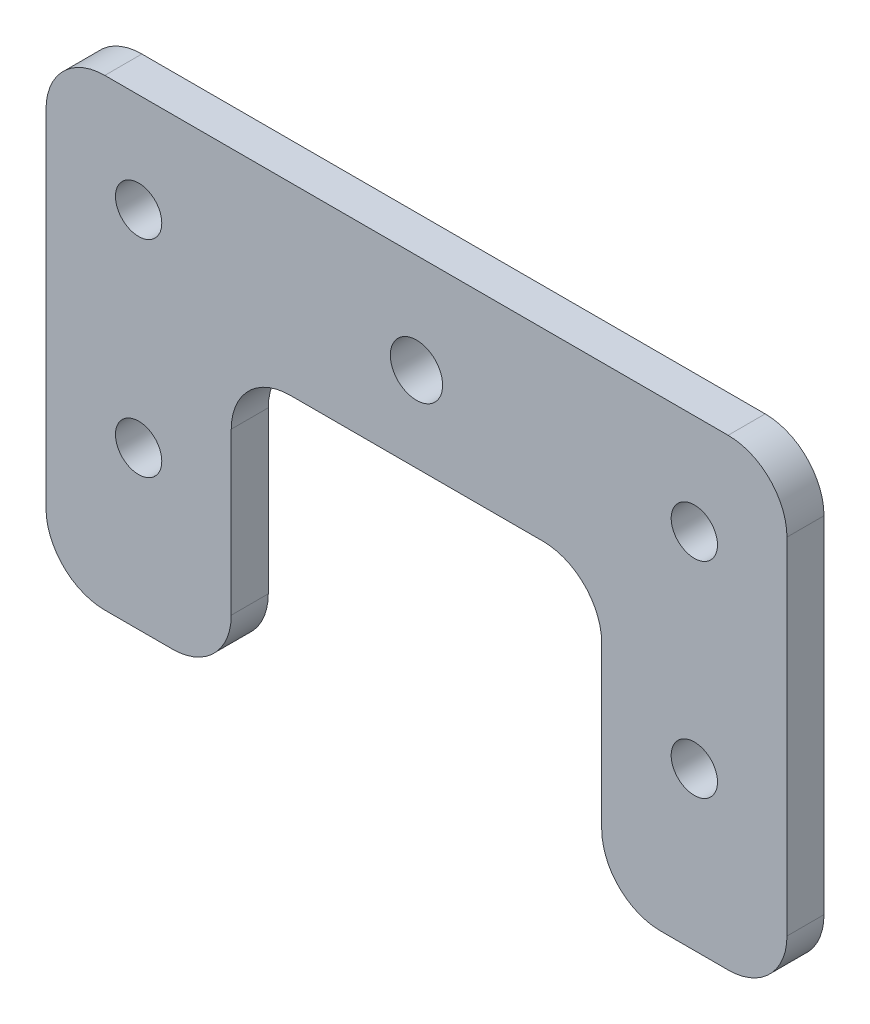
from build123d import *

# Parameters (mm, degrees)
CROQUIS1_R              = 2.5
CROQUIS1_R_2            = 2.821368504
SALIENTE_EXTRUIR1_DEPTH = 4


with BuildPart() as part:
    # Croquis1 → Saliente-Extruir1 (new body)
    with BuildSketch(Plane.XY):
        with BuildLine():
            Line((26.538050923, 6.699416954), (53.838050923, 6.699416954))
            ThreePointArc((53.838050923, 6.699416954), (58.328178983, 4.839545014), (60.188050923, 0.349416954))
            Line((60.188050923, 0.349416954), (60.188050923, -17.045643676))
            ThreePointArc((60.188050923, -17.045643676), (62.047922862, -21.535771736), (66.538050923, -23.395643676))
            Line((66.538050923, -23.395643676), (73.838050923, -23.395643676))
            ThreePointArc((73.838050923, -23.395643676), (78.328178983, -21.535771736), (80.188050923, -17.045643676))
            Line((80.188050923, -17.045643676), (80.188050923, 6.604356324))
            Line((80.188050923, 6.604356324), (80.188050923, 20.254356324))
            ThreePointArc((80.188050923, 20.254356324), (78.328178983, 24.744484385), (73.838050923, 26.604356324))
            Line((73.838050923, 26.604356324), (6.538050923, 26.604356324))
            ThreePointArc((6.538050923, 26.604356324), (2.047922862, 24.744484385), (0.188050923, 20.254356324))
            Line((0.188050923, 20.254356324), (0.188050923, 6.604356324))
            Line((0.188050923, 6.604356324), (0.188050923, -17.045643676))
            ThreePointArc((0.188050923, -17.045643676), (2.047922862, -21.535771736), (6.538050923, -23.395643676))
            Line((6.538050923, -23.395643676), (13.838050923, -23.395643676))
            ThreePointArc((13.838050923, -23.395643676), (18.328178983, -21.535771736), (20.188050923, -17.045643676))
            Line((20.188050923, -17.045643676), (20.188050923, 0.349416954))
            ThreePointArc((20.188050923, 0.349416954), (22.047922862, 4.839545014), (26.538050923, 6.699416954))
        make_face()
        with Locations((10.188050923, 15.866498333)):
            Circle(CROQUIS1_R, mode=Mode.SUBTRACT)
        with Locations((70.188050923, 15.771437703)):
            Circle(CROQUIS1_R, mode=Mode.SUBTRACT)
        with Locations((10.188050923, -6.395643676)):
            Circle(CROQUIS1_R, mode=Mode.SUBTRACT)
        with Locations((40.188050923, 15.866498333)):
            Circle(CROQUIS1_R_2, mode=Mode.SUBTRACT)
        with Locations((70.188050923, -6.395643676)):
            Circle(CROQUIS1_R, mode=Mode.SUBTRACT)
    extrude(amount=SALIENTE_EXTRUIR1_DEPTH)


solid = part.part
